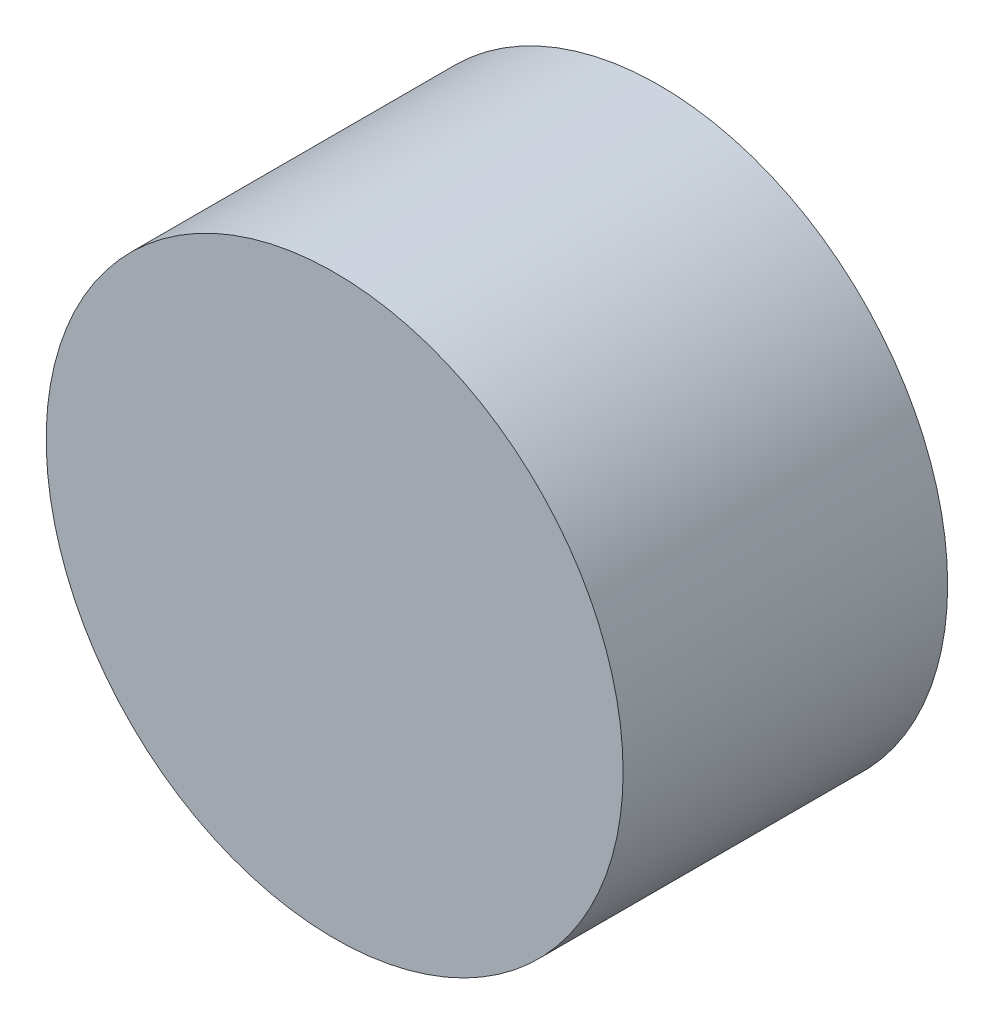
from build123d import *

# Parameters (mm, degrees)
SZKIC1_R                    = 80
DODANIE_WYCI_GNI_CIE1_DEPTH = 90


with BuildPart() as part:
    # Szkic1 → Dodanie-wyciągnięcie1 (new body)
    with BuildSketch(Plane.XY):
        Circle(SZKIC1_R)
    extrude(amount=-DODANIE_WYCI_GNI_CIE1_DEPTH)


solid = part.part
